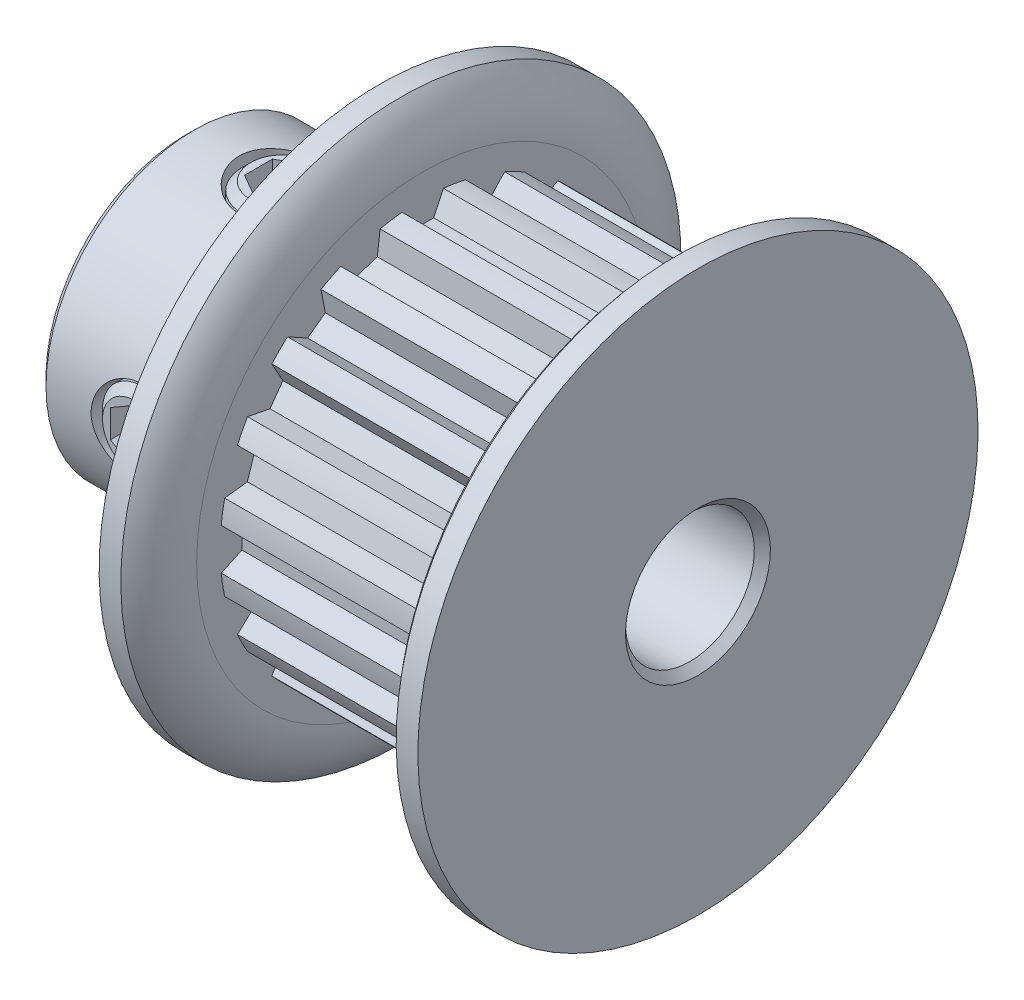
from build123d import *

# Parameters (mm, degrees)
SKETCH4_R          = 6.45
SKETCH4_R_2        = 6.29125
CUT_EXTRUDE2_DEPTH = 7.2
CUT_EXTRUDE1_DEPTH = 7.2
CIRPATTERN1_COUNT  = 20
SKETCH6_R          = 1.35
CUT_EXTRUDE3_DEPTH = 15.648634749
CUT_EXTRUDE4_DEPTH = 1.016
CIRPATTERN2_COUNT  = 2
CIRPATTERN2_ANGLE  = 90
CIRPATTERN3_COUNT  = 2
CIRPATTERN3_ANGLE  = 90
CHAMFER1_SIZE      = 0.25


with BuildPart() as part:
    # Sketch1 → Revolve1 (revolve)
    with BuildSketch(Plane.XY, mode=Mode.PRIVATE) as revolve1_sk:
        with BuildLine():
            Line((-7.95, 2), (7.95, 2))
            Line((7.95, 2), (7.95, 8.7))
            Line((7.95, 8.7), (7.275, 8.7))
            ThreePointArc((7.275, 8.7), (6.775071033, 7.92606996), (6.6, 7.0215))
            Line((6.6, 7.0215), (6.6, 6.45))
            Line((6.6, 6.45), (-0.6, 6.45))
            Line((-0.6, 6.45), (-0.6, 7.0215))
            ThreePointArc((-0.6, 7.0215), (-0.775071033, 7.92606996), (-1.275, 8.7))
            Line((-1.275, 8.7), (-1.95, 8.7))
            Line((-1.95, 8.7), (-1.95, 4.6))
            Line((-1.95, 4.6), (-7.95, 4.6))
            Line((-7.95, 4.6), (-7.95, 2))
        make_face()
    revolve(revolve1_sk.sketch.rotate(Axis((-7.95, 0, 0), (1, 0, 0)), 180), axis=Axis((-7.95, 0, 0), (1, 0, 0)))

    # Sketch4 → Cut-Extrude2 (cut)
    with BuildSketch(Plane(origin=(-0.6, 0, 0), x_dir=(0, 0, -1), z_dir=(1, 0, 0))):
        Circle(SKETCH4_R)
        with Locations(Location((0, 0, 0), (0, 0, 90))):
            Circle(SKETCH4_R_2, mode=Mode.SUBTRACT)
    extrude(amount=CUT_EXTRUDE2_DEPTH, mode=Mode.SUBTRACT)

    # Sketch3 → Cut-Extrude1 (cut)
    with BuildSketch(Plane(origin=(-0.6, 0, 0), x_dir=(0, 0, -1), z_dir=(1, 0, 0))):
        with BuildLine():
            Line((-0.642626263, 6.258343075), (-0.342201625, 5.614080361))
            Line((-0.342201625, 5.614080361), (0.342201625, 5.614080361))
            Line((0.342201625, 5.614080361), (0.642626263, 6.258343075))
            ThreePointArc((0.642626263, 6.258343075), (0, 6.29125), (-0.642626263, 6.258343075))
        make_face()
    cut_extrude1 = extrude(amount=CUT_EXTRUDE1_DEPTH, mode=Mode.SUBTRACT)

    # CirPattern1: Cut-Extrude1 ×20 about axis
    cirpattern1_axis = Axis((0, 0, 0), (1, 0, 0))
    for i in range(1, CIRPATTERN1_COUNT):
        add(cut_extrude1.rotate(cirpattern1_axis, i * 360 / CIRPATTERN1_COUNT), mode=Mode.SUBTRACT)

    # Sketch6 → Cut-Extrude3 (cut, through all)
    with BuildSketch(Plane(origin=(0, 0, 0), x_dir=(1, 0, 0), z_dir=(0, 1, 0))):
        with Locations(Location((-4.95, 0, 0), (0, 0, 90))):
            Circle(SKETCH6_R)
    cut_extrude3 = extrude(amount=CUT_EXTRUDE3_DEPTH, mode=Mode.SUBTRACT)

    # CirPattern2: Cut-Extrude3 ×2 about axis
    cirpattern2_axis = Axis((-7.95, 0, 0), (1, 0, 0))
    for i in range(1, CIRPATTERN2_COUNT):
        add(cut_extrude3.rotate(cirpattern2_axis, i * CIRPATTERN2_ANGLE / (CIRPATTERN2_COUNT - 1)), mode=Mode.SUBTRACT)

    # Chamfer1
    chamfer1_edges = [part.edges().sort_by_distance(p)[0] for p in [
        (7.95, 2, 0),
        (-7.95, 2, 0),
        (-7.95, 4.6, 0),
    ]]
    chamfer(chamfer1_edges, length=CHAMFER1_SIZE)


with BuildPart() as body_2:
    # Sketch7 → Revolve2 (revolve)
    with BuildSketch(Plane.XY, mode=Mode.PRIVATE) as revolve2_sk:
        Polygon((-5.946, 4.6), (-4.95, 4.6), (-4.95, 2.381), (-5.946, 2.381), (-6.2, 2.635), (-6.2, 4.346), align=None)
    revolve(revolve2_sk.sketch.rotate(Axis((-4.95, 2.381, 0), (0, 1, 0)), 270), axis=Axis((-4.95, 2.381, 0), (0, 1, 0)))

    # Sketch8 → Cut-Extrude4 (cut)
    with BuildSketch(Plane(origin=(0, 4.6, 0), x_dir=(1, 0, 0), z_dir=(0, 1, 0))):
        Polygon((-4.95, 0.866025404), (-5.7, 0.433012702), (-5.7, -0.433012702), (-4.95, -0.866025404), (-4.2, -0.433012702), (-4.2, 0.433012702), align=None)
    extrude(amount=-CUT_EXTRUDE4_DEPTH, mode=Mode.SUBTRACT)


with BuildPart() as cirpattern3_1:
    # CirPattern3: pattern copy
    add(body_2.part.rotate(Axis((0, 0, 0), (1, 0, 0)), 1 * CIRPATTERN3_ANGLE / (CIRPATTERN3_COUNT - 1)))


solid = Compound([part.part, body_2.part, cirpattern3_1.part])
